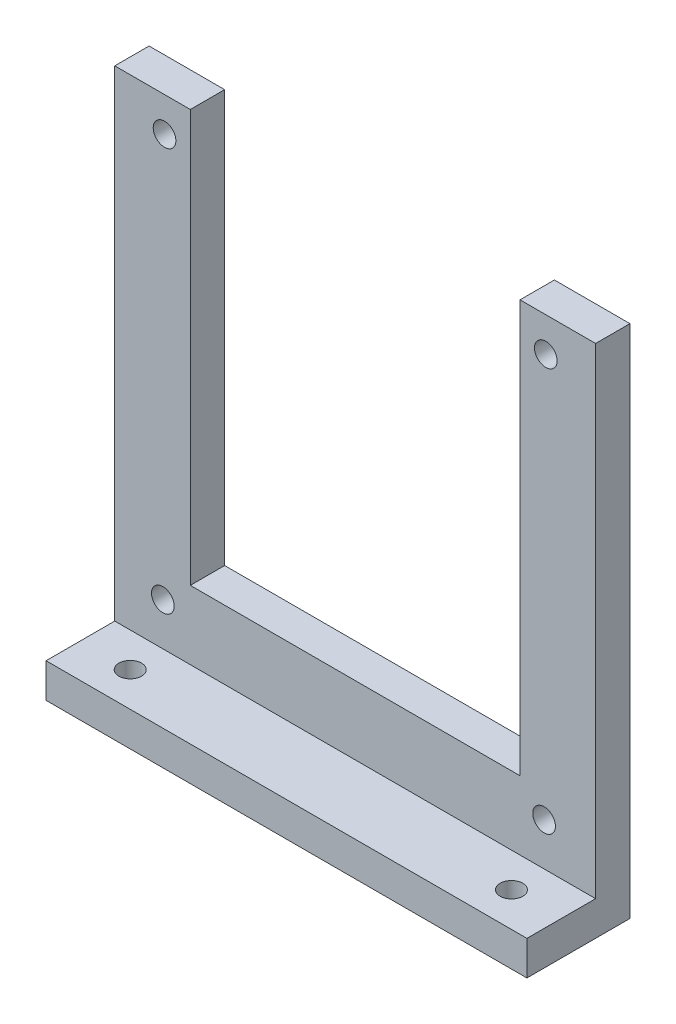
from build123d import *

# Parameters (mm, degrees)
SKIZZE1_W                       = 11
SKIZZE1_H                       = 60
SKIZZE1_H_2                     = 15
SKIZZE1_W_2                     = 48
AUFSATZ_LINEAR_AUSTRAGEN1_DEPTH = 5
SKIZZE2_R                       = 1.65
SCHNITT_LINEAR_AUSTRAGEN1_DEPTH = 5
SKIZZE6_W                       = 70
SKIZZE6_H                       = 5
AUFSATZ_LINEAR_AUSTRAGEN3_DEPTH = 10
SKIZZE7_R                       = 1.65
SCHNITT_LINEAR_AUSTRAGEN2_DEPTH = 10


with BuildPart() as part:
    # Skizze1 → Aufsatz-Linear austragen1 (new body)
    with BuildSketch(Plane.XY):
        with Locations((-29.5, 37.5)):
            Rectangle(SKIZZE1_W, SKIZZE1_H)
        with Locations((-29.5, 0)):
            Rectangle(SKIZZE1_W, SKIZZE1_H_2)
        Rectangle(SKIZZE1_W_2, SKIZZE1_H_2)
        with Locations((29.5, 0)):
            Rectangle(SKIZZE1_W, SKIZZE1_H_2)
        with Locations((29.5, 37.5)):
            Rectangle(SKIZZE1_W, SKIZZE1_H)
    extrude(amount=AUFSATZ_LINEAR_AUSTRAGEN1_DEPTH)

    # Skizze2 → Schnitt-Linear austragen1 (cut)
    with BuildSketch(Plane.XY.offset(5)):
        with Locations((-27.997843094, 3.700522334)):
            Circle(SKIZZE2_R)
        with Locations((27.502156906, 3.700522334)):
            Circle(SKIZZE2_R)
        with Locations((27.75, 62.5)):
            Circle(SKIZZE2_R)
        with Locations((-27.75, 62.5)):
            Circle(SKIZZE2_R)
    extrude(amount=-SCHNITT_LINEAR_AUSTRAGEN1_DEPTH, mode=Mode.SUBTRACT)

    # Skizze6 → Aufsatz-Linear austragen3 (add)
    with BuildSketch(Plane.XY.offset(5)):
        with Locations((0, -5)):
            Rectangle(SKIZZE6_W, SKIZZE6_H)
    extrude(amount=AUFSATZ_LINEAR_AUSTRAGEN3_DEPTH)

    # Skizze7 → Schnitt-Linear austragen2 (cut)
    with BuildSketch(Plane(origin=(0, -2.5, 0), x_dir=(1, 0, 0), z_dir=(0, 1, 0))):
        with Locations((-27.75, -10)):
            Circle(SKIZZE7_R)
        with Locations((27.75, -10)):
            Circle(SKIZZE7_R)
    extrude(amount=-SCHNITT_LINEAR_AUSTRAGEN2_DEPTH, mode=Mode.SUBTRACT)


solid = part.part
